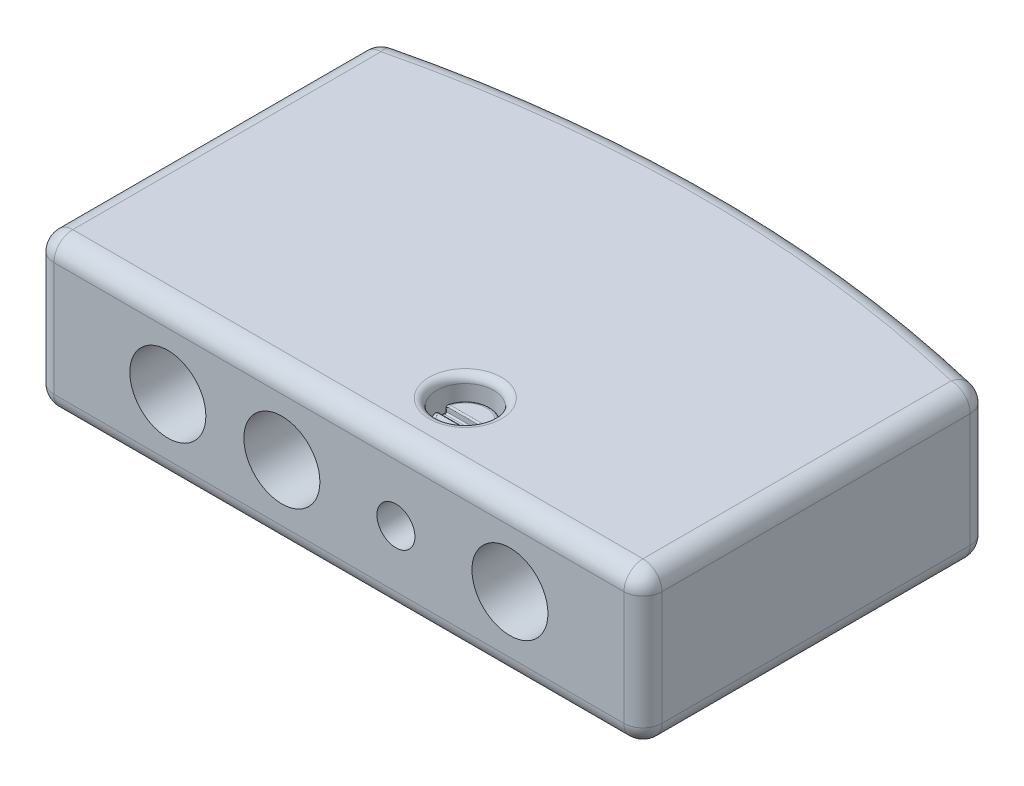
from build123d import *

# Parameters (mm, degrees)
BOSS_EXTRUDE1_DEPTH  = 5
CUT_EXTRUDE1_DEPTH   = 5
SKETCH3_R            = 0.5000000000000001
SKETCH3_R_2          = 0.5
SKETCH3_R_3          = 0.24999999999999994
SKETCH3_R_4          = 0.4999999999999999
CUT_EXTRUDE2_DEPTH   = 2
FILLET1_R            = 0.25
SKETCH4_R            = 0.375
CUT_EXTRUDE3_DEPTH   = 0.5
SKETCH5_R            = 0.3249999999999999
BOSS_EXTRUDE2_DEPTH  = 0.25
SKETCH6_W            = 0.6928806512501648
SKETCH6_H            = 0.13374207919479897
CUT_EXTRUDE4_DEPTH   = 0.1
FILLET2_R            = 0.1
FILLET3_R            = 0.05
FILLET2_OF_MIRROR3_R = 0.1
FILLET3_OF_MIRROR3_R = 0.05
FILLET4_R            = 0.02
FILLET5_R            = 0.02


with BuildPart() as part:
    # Sketch1 → Boss-Extrude1 (new body)
    with BuildSketch(Plane.XY):
        Polygon((-3.999999999999999, 1), (4.000000000000002, 1), (4.000000000000001, -0.9999999999999996), (-3.999999999999999, -0.9999999999999991), align=None)
    extrude(amount=BOSS_EXTRUDE1_DEPTH)

    # Sketch2 → Cut-Extrude1 (cut)
    with BuildSketch(Plane(origin=(0, 1, 0), x_dir=(1, 0, 0), z_dir=(0, 1, 0))):
        with BuildLine():
            Line((-3.999999999999999, 0), (-3.999999999999999, -0.4999999999999991))
            ThreePointArc((-3.9999999999999996, -0.4999999999999982), (-2.0155644370746333, -0.12548450340290174), (7.22e-15, 0))
            Line((7.11e-15, 0), (-3.9999999999999982, 0))
        make_face()
        with BuildLine():
            Line((4.000000000000002, 0), (7.11e-15, 0))
            ThreePointArc((7.22e-15, 0), (2.015564437074642, -0.12548450340289818), (4.000000000000002, -0.4999999999999982))
            Line((4.000000000000002, -0.4999999999999991), (4.000000000000002, 0))
        make_face()
    extrude(amount=-CUT_EXTRUDE1_DEPTH, mode=Mode.SUBTRACT)

    # Sketch3 → Cut-Extrude2 (cut)
    with BuildSketch(Plane.XY.offset(5)):
        with Locations((-2.2500000000000004, 0)):
            Circle(SKETCH3_R)
        with Locations((-0.7500000000000002, 0)):
            Circle(SKETCH3_R_2)
        with Locations((0.7500000000000002, 0)):
            Circle(SKETCH3_R_3)
        with Locations((2.2500000000000004, 0)):
            Circle(SKETCH3_R_4)
    extrude(amount=-CUT_EXTRUDE2_DEPTH, mode=Mode.SUBTRACT)

    # Fillet1
    fillet1_edges = [part.edges().sort_by_distance(p)[0] for p in [
        (4.000000000000002, 2.2e-16, 5),
        (8.9e-16, 1, 5),
        (-3.999999999999999, 4.4e-16, 0.49999999999999867),
        (6.7e-16, -0.9999999999999993, 0),
        (6.7e-16, 1, 0),
        (4.000000000000002, 2.2e-16, 0.49999999999999867),
        (-3.999999999999999, 4.4e-16, 5),
        (8.9e-16, -0.9999999999999993, 5),
        (-3.999999999999999, 1, 2.7499999999999996),
        (4.000000000000002, 1, 2.7499999999999996),
        (4.000000000000001, -0.9999999999999996, 2.7499999999999996),
        (-3.999999999999999, -0.9999999999999991, 2.7499999999999996),
    ]]
    fillet(fillet1_edges, radius=FILLET1_R)

    # Sketch4 → Cut-Extrude3 (cut)
    with BuildSketch(Plane(origin=(0, 1, 0), x_dir=(1, 0, 0), z_dir=(0, 1, 0))):
        with Locations(Location((0.7500000000000002, -4.0870181644865085, 0), (0, 0, 270))):
            Circle(SKETCH4_R)
    cut_extrude3 = extrude(amount=-CUT_EXTRUDE3_DEPTH, mode=Mode.SUBTRACT)

    # Sketch5 → Boss-Extrude2 (add)
    with BuildSketch(Plane(origin=(0, 0.5, 0), x_dir=(1, 0, 0), z_dir=(0, 1, 0))):
        with Locations(Location((0.7500000000000002, -4.0870181644865085, 0), (0, 0, 270))):
            Circle(SKETCH5_R)
    boss_extrude2 = extrude(amount=BOSS_EXTRUDE2_DEPTH)

    # Sketch6 → Cut-Extrude4 (cut)
    with BuildSketch(Plane(origin=(0, 0.75, 0), x_dir=(-1, 0, 0), z_dir=(0, 1, 0))):
        with Locations((-0.7474919939297356, 4.103079752618154)):
            Rectangle(SKETCH6_W, SKETCH6_H)
    cut_extrude4 = extrude(amount=-CUT_EXTRUDE4_DEPTH, mode=Mode.SUBTRACT)

    # Fillet2
    fillet2_edges = [part.edges().sort_by_distance(p)[0] for p in [
        (0.7500000000000003, 1, 3.7120181644865085),
    ]]
    fillet(fillet2_edges, radius=FILLET2_R)

    # Fillet3
    fillet3_edges = [part.edges().sort_by_distance(p)[0] for p in [
        (0.7500000000000003, 0.75, 3.7620181644865087),
        (0.9483329221133731, 0.75, 4.3444847681576855),
    ]]
    fillet(fillet3_edges, radius=FILLET3_R)

    # Mirror3: Cut-Extrude3, Boss-Extrude2, Cut-Extrude4 across plane
    add(cut_extrude3.mirror(Plane.ZX), mode=Mode.SUBTRACT)
    add(boss_extrude2.mirror(Plane.ZX))
    add(cut_extrude4.mirror(Plane.ZX), mode=Mode.SUBTRACT)

    # Fillet2 of Mirror3
    fillet2_of_mirror3_edges = [part.edges().sort_by_distance(p)[0] for p in [
        (0.7500000000000003, -1, 3.7120181644865085),
    ]]
    fillet(fillet2_of_mirror3_edges, radius=FILLET2_OF_MIRROR3_R)

    # Fillet3 of Mirror3
    fillet3_of_mirror3_edges = [part.edges().sort_by_distance(p)[0] for p in [
        (0.7500000000000003, -0.75, 3.7620181644865087),
        (0.9483329221133731, -0.75, 4.3444847681576855),
    ]]
    fillet(fillet3_of_mirror3_edges, radius=FILLET3_OF_MIRROR3_R)

    # Fillet4
    fillet4_edges = [part.edges().sort_by_distance(p)[0] for p in [
        (0.42541474076774405, 0.65, 4.103431862702602),
        (1.0745852592322565, 0.65, 4.103431862702602),
        (0.7500000000000002, 0.65, 4.036208713020754),
        (0.4289962622620277, 0.675, 4.036208713020754),
        (0.7500000000000002, 0.65, 4.169950792215553),
        (1.0642406390936026, 0.675, 4.169950792215553),
        (0.7500000000000002, 0.75, 4.169950792215553),
        (0.43575936090639783, 0.675, 4.169950792215553),
        (0.4513394924992421, 0.7357451704602401, 4.169950792215553),
        (1.048660507500758, 0.73574517046024, 4.169950792215553),
        (1.0710037377379726, 0.675, 4.036208713020754),
        (0.7500000000000002, 0.75, 4.036208713020754),
        (1.056022937413614, 0.735497850599935, 4.036208713020754),
        (0.4439770625863861, 0.7354978505999351, 4.036208713020754),
    ]]
    fillet(fillet4_edges, radius=FILLET4_R)

    # Fillet5
    fillet5_edges = [part.edges().sort_by_distance(p)[0] for p in [
        (1.0745852592322565, -0.65, 4.103431862702602),
        (0.7500000000000002, -0.65, 4.036208713020754),
        (0.42541474076774405, -0.65, 4.103431862702602),
        (0.7500000000000002, -0.65, 4.169950792215553),
        (0.7500000000000002, -0.75, 4.169950792215553),
        (1.048660507500758, -0.73574517046024, 4.169950792215553),
        (0.4513394924992421, -0.7357451704602401, 4.169950792215553),
        (1.0642406390936026, -0.675, 4.169950792215553),
        (0.43575936090639783, -0.675, 4.169950792215553),
        (0.4289962622620277, -0.675, 4.036208713020754),
        (1.0710037377379726, -0.675, 4.036208713020754),
        (0.7500000000000002, -0.75, 4.036208713020754),
        (0.4439770625863861, -0.7354978505999351, 4.036208713020754),
        (1.056022937413614, -0.735497850599935, 4.036208713020754),
    ]]
    fillet(fillet5_edges, radius=FILLET5_R)


solid = part.part
